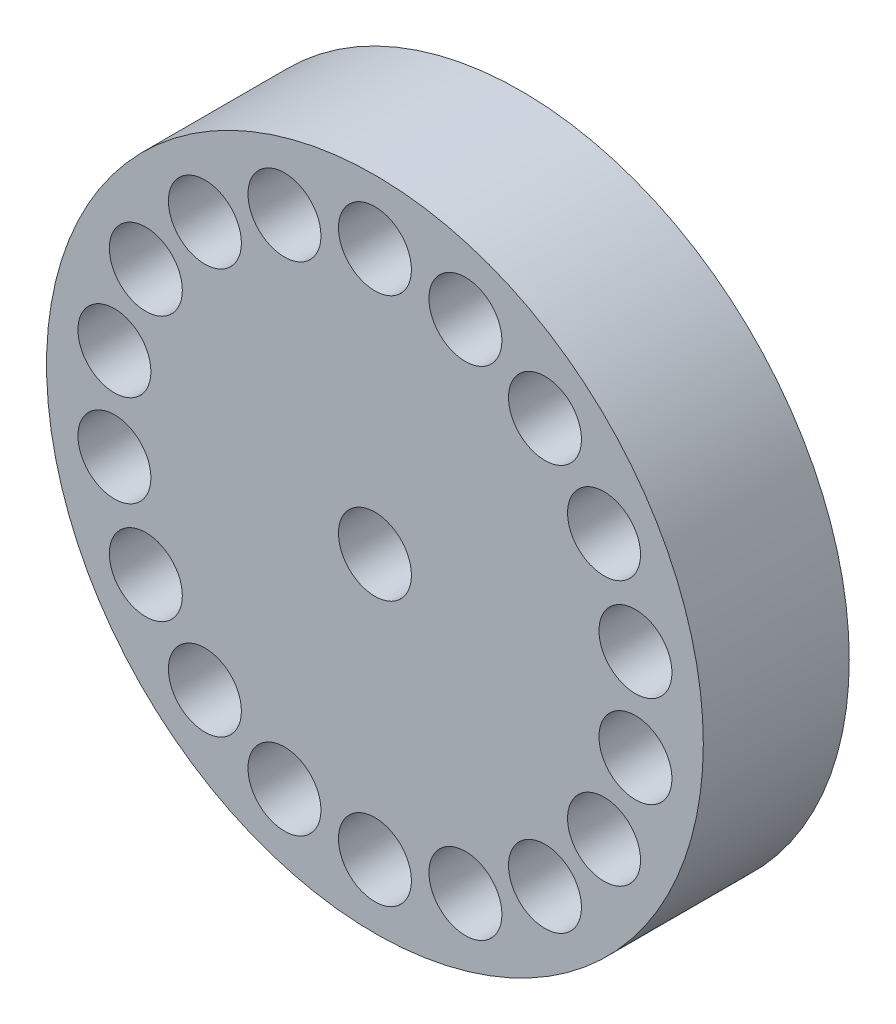
from build123d import *

# Parameters (mm, degrees)
SZKIC1_R                    = 4.5
SZKIC1_R_2                  = 0.5
DODANIE_WYCI_GNI_CIE1_DEPTH = 2
SZKIC2_R                    = 0.5
WYTNIJ_WYCI_GNI_CIE2_DEPTH  = 1


with BuildPart() as part:
    # Szkic1 → Dodanie-wyciągnięcie1 (new body)
    with BuildSketch(Plane.XY):
        Circle(SZKIC1_R)
        Circle(SZKIC1_R_2, mode=Mode.SUBTRACT)
    extrude(amount=DODANIE_WYCI_GNI_CIE1_DEPTH)

    # Szkic2 → Wytnij-wyciągnięcie2 (cut)
    with BuildSketch(Plane.XY.offset(2)):
        with Locations((0, 3.625)):
            Circle(SZKIC2_R)
        with Locations((1.23982302, 3.40638575)):
            Circle(SZKIC2_R)
        with Locations((2.330105085, 2.776911106)):
            Circle(SZKIC2_R)
        with Locations((3.139342089, 1.8125)):
            Circle(SZKIC2_R)
        with Locations((3.569928105, 0.629474644)):
            Circle(SZKIC2_R)
        with Locations((3.569928105, -0.629474644)):
            Circle(SZKIC2_R)
        with Locations((3.139342089, -1.8125)):
            Circle(SZKIC2_R)
        with Locations((2.330105085, -2.776911106)):
            Circle(SZKIC2_R)
        with Locations((1.23982302, -3.40638575)):
            Circle(SZKIC2_R)
        with Locations((0, -3.625)):
            Circle(SZKIC2_R)
        with Locations((-1.23982302, -3.40638575)):
            Circle(SZKIC2_R)
        with Locations((-2.330105085, -2.776911106)):
            Circle(SZKIC2_R)
        with Locations((-3.139342089, -1.8125)):
            Circle(SZKIC2_R)
        with Locations((-3.569928105, -0.629474644)):
            Circle(SZKIC2_R)
        with Locations((-3.569928105, 0.629474644)):
            Circle(SZKIC2_R)
        with Locations((-3.139342089, 1.8125)):
            Circle(SZKIC2_R)
        with Locations((-2.330105085, 2.776911106)):
            Circle(SZKIC2_R)
        with Locations((-1.23982302, 3.40638575)):
            Circle(SZKIC2_R)
    extrude(amount=-WYTNIJ_WYCI_GNI_CIE2_DEPTH, mode=Mode.SUBTRACT)


solid = part.part
